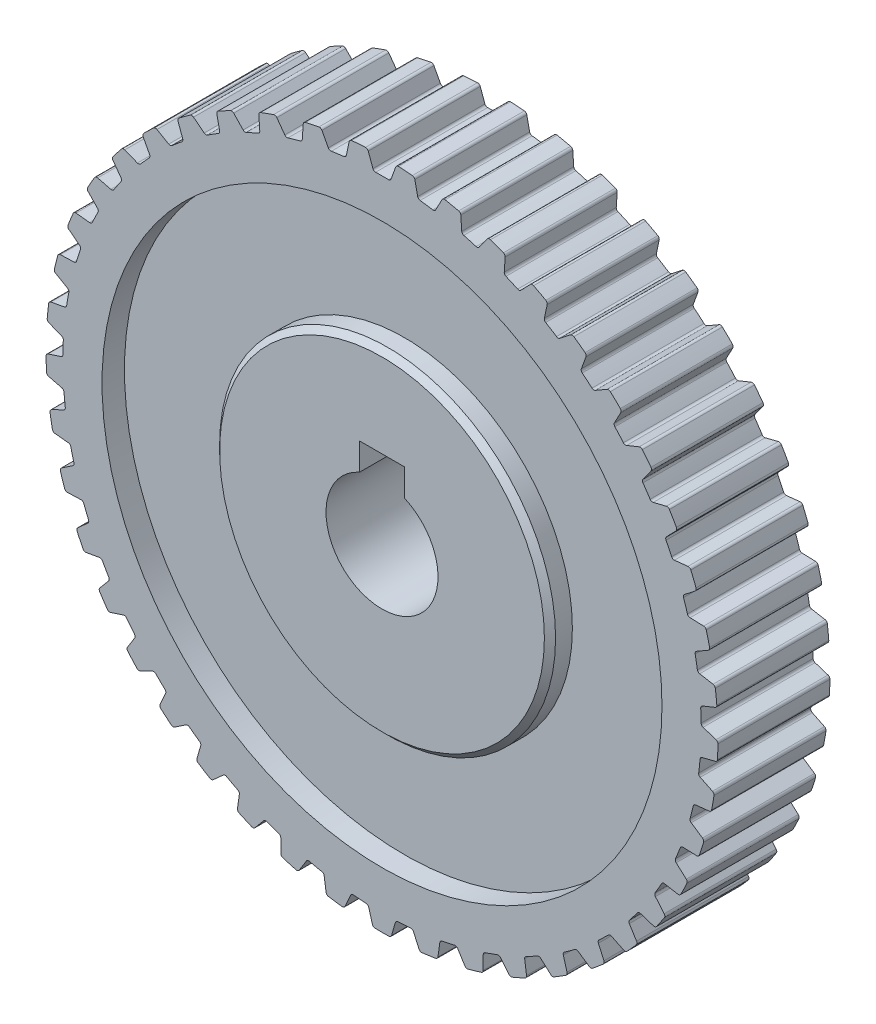
from build123d import *

# Parameters (mm, degrees)
SKETCH2_R               = 30
BOSS_EXTRUDE1_DEPTH     = 5
CUT_EXTRUDE1_DEPTH      = 11
CIRPATTERN1_COUNT       = 45
SKETCH4_R               = 25
SKETCH4_R_2             = 15
CUT_EXTRUDE_THIN1_DEPTH = 2
CHAMFER1_SIZE           = 0.5
CHAMFER2_SIZE           = 0.5
FILLET1_R               = 0.25


with BuildPart() as part:
    # Sketch2 → Boss-Extrude1 (new body, symmetric)
    with BuildSketch(Plane.XY):
        Circle(SKETCH2_R)
        with BuildLine():
            Line((-2, 7), (2, 7))
            Line((2, 7), (2, 4.582575695))
            ThreePointArc((2, 4.582575695), (0, -5), (-2, 4.582575695))
            Line((-2, 4.582575695), (-2, 7))
        make_face(mode=Mode.SUBTRACT)
    extrude(amount=BOSS_EXTRUDE1_DEPTH, both=True)

    # Sketch3 → Cut-Extrude1 (cut, through all)
    with BuildSketch(Plane.XY.offset(5)):
        with BuildLine():
            Line((-50.980845161, 166.498242709), (-1.289456906, 29.972275537))
            Line((-1.289456906, 29.972275537), (-0.75, 28.49012987))
            ThreePointArc((-0.75, 28.49012987), (0, 28.5), (0.75, 28.49012987))
            Line((0.75, 28.49012987), (1.289456906, 29.972275537))
            Line((1.289456906, 29.972275537), (50.980845161, 166.498242709))
            Line((50.980845161, 166.498242709), (50.980845161, 457.07404197))
            Line((50.980845161, 457.07404197), (-50.980845161, 457.07404197))
            Line((-50.980845161, 457.07404197), (-50.980845161, 166.498242709))
        make_face()
    cut_extrude1 = extrude(amount=-CUT_EXTRUDE1_DEPTH, mode=Mode.SUBTRACT)

    # CirPattern1: Cut-Extrude1 ×45 about axis
    cirpattern1_axis = Axis((0, 0, 0), (0, 0, 1))
    for i in range(1, CIRPATTERN1_COUNT):
        add(cut_extrude1.rotate(cirpattern1_axis, i * 360 / CIRPATTERN1_COUNT), mode=Mode.SUBTRACT)

    # Sketch4 → Cut-Extrude-Thin1 (cut)
    with BuildSketch(Plane.XY.offset(5)):
        Circle(SKETCH4_R)
        Circle(SKETCH4_R_2, mode=Mode.SUBTRACT)
    cut_extrude_thin1 = extrude(amount=-CUT_EXTRUDE_THIN1_DEPTH, mode=Mode.SUBTRACT)

    # Chamfer1
    chamfer1_edges = [part.edges().sort_by_distance(p)[0] for p in [
        (-15, 0, 5),
    ]]
    chamfer(chamfer1_edges, length=CHAMFER1_SIZE)

    # Mirror2: Cut-Extrude-Thin1 across plane
    add(cut_extrude_thin1.mirror(Plane.XY), mode=Mode.SUBTRACT)

    # Chamfer2
    chamfer2_edges = [part.edges().sort_by_distance(p)[0] for p in [
        (-15, 0, -5),
    ]]
    chamfer(chamfer2_edges, length=CHAMFER2_SIZE)

    # Fillet1
    fillet1_edges = [part.edges().sort_by_distance(p)[0] for p in [
        (28.25566161, -3.723920915, 0),
        (28.412454305, -2.232138072, 0),
        (29.942869225, -1.850562777, 0),
        (0.75, 28.49012987, 0),
        (29.673299327, -4.415349029, 0),
        (-0.75, 28.49012987, 0),
        (27.462409832, -7.620108019, 0),
        (27.825292675, -6.164664429, 0),
        (29.39391872, -5.999795188, 0),
        (28.770023002, -8.502104238, 0),
        (-1.289456906, 29.972275537, 0),
        (26.134633485, -11.367978387, 0),
        (26.696543375, -9.977202606, 0),
        (28.272849022, -10.032248412, 0),
        (27.306770904, -12.42337566, 0),
        (1.289456906, 29.972275537, 0),
        (24.298176224, -14.894583988, 0),
        (25.048176224, -13.595545882, 0),
        (26.601480478, -13.869435331, 0),
        (25.312023572, -16.102840206, 0),
        (21.988782603, -18.131283453, 0),
        (22.912274816, -16.949267323, 0),
        (24.412344375, -17.436669468, 0),
        (22.824606492, -19.468881284, 0),
        (19.251402339, -21.01507811, 0),
        (20.33041204, -19.973090554, 0),
        (21.748049757, -20.664518668, 0),
        (19.892934411, -22.455982734, 0),
        (16.139315428, -23.489838176, 0),
        (17.352840919, -22.608160297, 0),
        (18.660454089, -23.490156517, 0),
        (16.574068988, -25.006004023, 0),
        (12.713095099, -25.507395261, 0),
        (14.037516489, -24.803187917, 0),
        (15.209653908, -25.85858519, 0),
        (12.932608166, -27.069311887, 0),
        (9.039428836, -27.028479911, 0),
        (10.448967767, -26.515449696, 0),
        (11.462815114, -27.723705915, 0),
        (9.039428836, -28.605746386, 0),
        (5.189820372, -28.023485945, 0),
        (6.657041773, -27.711618409, 0),
        (7.492865663, -29.04921624, 0),
        (4.970307306, -29.585402571, 0),
        (1.239197959, -28.473046701, 0),
        (2.735544034, -28.36841199, 0),
        (3.377076105, -29.809316614, 0),
        (0.804444398, -29.989212547, 0),
        (-2.735544034, -28.36841199, 0),
        (-1.239197959, -28.473046701, 0),
        (-0.804444398, -29.989212547, 0),
        (-3.377076105, -29.809316614, 0),
        (-6.657041773, -27.711618409, 0),
        (-5.189820372, -28.023485945, 0),
        (-4.970307306, -29.585402571, 0),
        (-7.492865663, -29.04921624, 0),
        (-10.448967767, -26.515449696, 0),
        (-9.039428836, -27.028479911, 0),
        (-9.039428836, -28.605746386, 0),
        (-11.462815114, -27.723705915, 0),
        (-14.037516489, -24.803187917, 0),
        (-12.713095099, -25.507395261, 0),
        (-12.932608166, -27.069311887, 0),
        (-15.209653908, -25.85858519, 0),
        (-17.352840919, -22.608160297, 0),
        (-16.139315428, -23.489838176, 0),
        (-16.574068988, -25.006004023, 0),
        (-18.660454089, -23.490156517, 0),
        (-20.33041204, -19.973090554, 0),
        (-19.251402339, -21.01507811, 0),
        (-19.892934411, -22.455982734, 0),
        (-21.748049757, -20.664518668, 0),
        (-22.912274816, -16.949267323, 0),
        (-21.988782603, -18.131283453, 0),
        (-22.824606492, -19.468881284, 0),
        (-24.412344375, -17.436669468, 0),
        (-25.048176224, -13.595545882, 0),
        (-24.298176224, -14.894583988, 0),
        (-25.312023572, -16.102840206, 0),
        (-26.601480478, -13.869435331, 0),
        (-26.696543375, -9.977202606, 0),
        (-26.134633485, -11.367978387, 0),
        (-27.306770904, -12.42337566, 0),
        (-28.272849022, -10.032248412, 0),
        (-27.825292675, -6.164664429, 0),
        (-27.462409832, -7.620108019, 0),
        (-28.770023002, -8.502104238, 0),
        (-29.39391872, -5.999795188, 0),
        (-28.412454305, -2.232138072, 0),
        (-28.25566161, -3.723920915, 0),
        (-29.673299327, -4.415349029, 0),
        (-29.942869225, -1.850562777, 0),
        (-28.44659983, 1.743834314, 0),
        (-28.498949075, 0.244748073, 0),
        (-29.999018634, -0.242654072, 0),
        (-29.90901584, 2.334688735, 0),
        (-27.927064647, 5.685864948, 0),
        (-28.187536913, 4.208653319, 0),
        (-29.740841166, 3.93476387, 0),
        (-29.293017483, 6.474498186, 0),
        (-26.863960917, 9.517226689, 0),
        (-27.327486409, 8.090641915, 0),
        (-28.903792055, 8.035596108, 0),
        (-28.106863861, 10.488288894, 0),
        (-25.277980745, 13.163346438, 0),
        (-25.935537465, 11.815155368, 0),
        (-27.50416351, 11.980024609, 0),
        (-26.373642104, 14.297936989, 0),
        (-23.199993431, 16.553256622, 0),
        (-24.038782787, 15.309700263, 0),
        (-25.569197707, 15.691275558, 0),
        (-24.127087404, 17.829292004, 0),
        (-20.670444635, 19.620976494, 0),
        (-21.674140545, 18.506259256, 0),
        (-23.136556555, 19.097113677, 0),
        (-21.410926392, 21.013620132, 0),
        (-17.738569146, 22.306796378, 0),
        (-18.887635811, 21.342614963, 0),
        (-20.253588647, 22.131248201, 0),
        (-18.278026052, 23.788942045, 0),
        (-14.461432586, 24.558439844, 0),
        (-15.733504731, 23.763560947, 0),
        (-16.976407674, 24.734623152, 0),
        (-14.789364726, 26.101239262, 0),
        (-10.902820691, 26.332081213, 0),
        (-12.273138877, 25.721976248, 0),
        (-13.368800237, 26.856566799, 0),
        (-11.012845238, 27.905505546, 0),
        (-7.131997792, 27.593198573, 0),
        (-8.573890336, 27.179742539, 0),
        (-9.500984309, 28.455777922, 0),
        (-7.021973245, 29.166622906, 0),
        (28.498949075, 0.244748073, 0),
        (28.44659983, 1.743834314, 0),
        (29.90901584, 2.334688735, 0),
        (29.999018634, -0.242654072, 0),
        (28.187536913, 4.208653319, 0),
        (27.927064647, 5.685864948, 0),
        (29.293017483, 6.474498186, 0),
        (29.740841166, 3.93476387, 0),
        (27.327486409, 8.090641915, 0),
        (26.863960917, 9.517226689, 0),
        (28.106863861, 10.488288894, 0),
        (28.903792055, 8.035596108, 0),
        (25.935537465, 11.815155368, 0),
        (25.277980745, 13.163346438, 0),
        (26.373642104, 14.297936989, 0),
        (27.50416351, 11.980024609, 0),
        (24.038782787, 15.309700263, 0),
        (23.199993431, 16.553256622, 0),
        (24.127087404, 17.829292004, 0),
        (25.569197707, 15.691275558, 0),
        (21.674140545, 18.506259256, 0),
        (20.670444635, 19.620976494, 0),
        (21.410926392, 21.013620132, 0),
        (23.136556555, 19.097113677, 0),
        (18.887635811, 21.342614963, 0),
        (17.738569146, 22.306796378, 0),
        (18.278026052, 23.788942045, 0),
        (20.253588647, 22.131248201, 0),
        (15.733504731, 23.763560947, 0),
        (14.461432586, 24.558439844, 0),
        (14.789364726, 26.101239262, 0),
        (16.976407674, 24.734623152, 0),
        (12.273138877, 25.721976248, 0),
        (10.902820691, 26.332081213, 0),
        (11.012845238, 27.905505546, 0),
        (13.368800237, 26.856566799, 0),
        (8.573890336, 27.179742539, 0),
        (7.131997792, 27.593198573, 0),
        (7.021973245, 29.166622906, 0),
        (9.500984309, 28.455777922, 0),
        (4.707760772, 28.108486059, 0),
        (3.222358669, 28.31724571, 0),
        (2.89442653, 29.860045128, 0),
        (5.448242529, 29.501129696, 0),
        (-3.222358669, 28.31724571, 0),
        (-4.707760772, 28.108486059, 0),
        (-5.448242529, 29.501129696, 0),
        (-2.89442653, 29.860045128, 0),
        (-25, 0, -5),
    ]]
    fillet(fillet1_edges, radius=FILLET1_R)


solid = part.part
